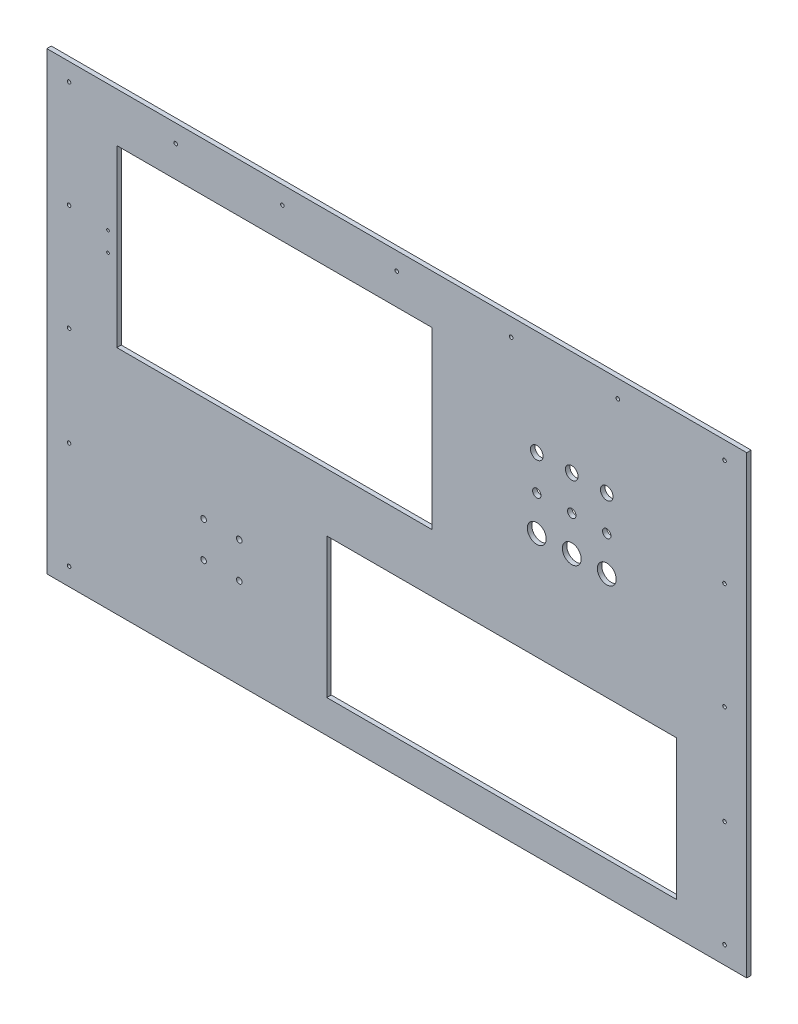
from build123d import *

# Parameters (mm, degrees)
SKETCH1_W                             = 1000
SKETCH1_H                             = 650
BOSS_EXTRUDE1_DEPTH                   = 6.35
SKETCH2_R                             = 9
SKETCH2_R_2                           = 4
SKETCH2_W                             = 500
SKETCH2_H                             = 200
SKETCH2_W_2                           = 450
SKETCH2_H_2                           = 250
CUT_EXTRUDE1_DEPTH                    = 6.35
F_10_CLEARANCE_HOLE1_MOUNTING_HOLES_D = 5.1054
M27_CLEARANCE_HOLE1_BUTTONS_D         = 27
F_12_0MM_DOWEL_HOLE1_SWITCHES_D       = 12
F_6_CLEARANCE_HOLE2_D                 = 3.7973


with BuildPart() as part:
    # Sketch1 → Boss-Extrude1 (new body)
    with BuildSketch(Plane.XY):
        with Locations((0, -55)):
            Rectangle(SKETCH1_W, SKETCH1_H)
    extrude(amount=BOSS_EXTRUDE1_DEPTH)

    # Sketch2 → Cut-Extrude1 (cut)
    with BuildSketch(Plane.XY):
        with Locations((300, 120)):
            Circle(SKETCH2_R)
        with Locations((250, 120)):
            Circle(SKETCH2_R)
        with Locations((200, 120)):
            Circle(SKETCH2_R)
        with Locations((-225, -251)):
            Circle(SKETCH2_R_2)
        with Locations((-225, -200)):
            Circle(SKETCH2_R_2)
        with Locations((-276, -200)):
            Circle(SKETCH2_R_2)
        with Locations((-276, -251)):
            Circle(SKETCH2_R_2)
        with Locations((150, -233)):
            Rectangle(SKETCH2_W, SKETCH2_H)
        with Locations((-175, 75)):
            Rectangle(SKETCH2_W_2, SKETCH2_H_2)
    extrude(amount=CUT_EXTRUDE1_DEPTH, mode=Mode.SUBTRACT)

    # #10 Clearance Hole1 - Mounting Holes (through all)
    with Locations(Plane(origin=(0, 0, 0), x_dir=(-1, 0, 0), z_dir=(0, 0, -1))):
        with Locations((-468.25, -354.6), (-468.25, -202.2), (-468.25, -60.2), (-468.25, 92.2), (-468.25, 244.6), (-315.85, 244.6), (-163.45, 244.6), (0, 244.6), (163.45, 244.6), (315.85, 244.6), (468.25, 244.6), (468.25, 92.2), (468.25, -354.6), (468.25, -202.2), (468.25, -60.2)):
            Hole(F_10_CLEARANCE_HOLE1_MOUNTING_HOLES_D / 2)

    # M27 Clearance Hole1 - Buttons (through all)
    with Locations(Plane(origin=(0, 0, 0), x_dir=(-1, 0, 0), z_dir=(0, 0, -1))):
        with Locations((-300, 20), (-250, 20), (-200, 20)):
            Hole(M27_CLEARANCE_HOLE1_BUTTONS_D / 2)

    # Ø12.0mm Dowel Hole1 - Switches (through all)
    with Locations(Plane(origin=(0, 0, 0), x_dir=(-1, 0, 0), z_dir=(0, 0, -1))):
        with Locations((-300, 70), (-250, 70), (-200, 70)):
            Hole(F_12_0MM_DOWEL_HOLE1_SWITCHES_D / 2)

    # #6 Clearance Hole2 (through all)
    with Locations(Plane(origin=(0, 0, 0), x_dir=(-1, 0, 0), z_dir=(0, 0, -1))):
        with Locations((412.55625, 89), (412.55625, 61)):
            Hole(F_6_CLEARANCE_HOLE2_D / 2)


solid = part.part
